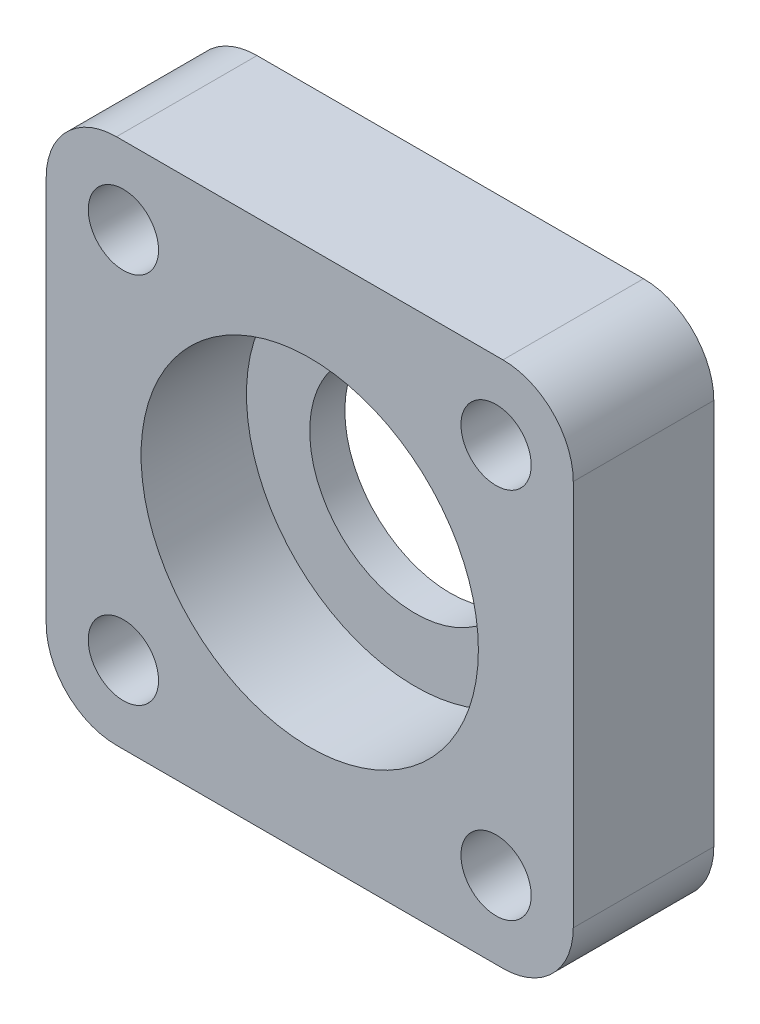
from build123d import *

# Parameters (mm, degrees)
SKETCH1_W           = 30
SKETCH1_H           = 30
SKETCH1_R           = 2
BOSS_EXTRUDE1_DEPTH = 8
SKETCH2_R           = 9.6
CUT_EXTRUDE1_DEPTH  = 6
SKETCH3_R           = 6
CUT_EXTRUDE2_DEPTH  = 7
FILLET1_R           = 4


with BuildPart() as part:
    # Sketch1 → Boss-Extrude1 (new body)
    with BuildSketch(Plane.XY):
        with Locations((15, 15)):
            Rectangle(SKETCH1_W, SKETCH1_H)
        with Locations((25.606601718, 25.606601718)):
            Circle(SKETCH1_R, mode=Mode.SUBTRACT)
        with Locations((25.606601718, 4.393398282)):
            Circle(SKETCH1_R, mode=Mode.SUBTRACT)
        with Locations((4.393398282, 4.393398282)):
            Circle(SKETCH1_R, mode=Mode.SUBTRACT)
        with Locations((4.393398282, 25.606601718)):
            Circle(SKETCH1_R, mode=Mode.SUBTRACT)
    extrude(amount=BOSS_EXTRUDE1_DEPTH)

    # Sketch2 → Cut-Extrude1 (cut)
    with BuildSketch(Plane.XY.offset(8)):
        with Locations((15, 15)):
            Circle(SKETCH2_R)
    extrude(amount=-CUT_EXTRUDE1_DEPTH, mode=Mode.SUBTRACT)

    # Sketch3 → Cut-Extrude2 (cut)
    with BuildSketch(Plane.XY.offset(2)):
        with Locations((15, 15)):
            Circle(SKETCH3_R)
    extrude(amount=-CUT_EXTRUDE2_DEPTH, mode=Mode.SUBTRACT)

    # Fillet1
    fillet1_edges = [part.edges().sort_by_distance(p)[0] for p in [
        (0, 30, 4),
        (30, 30, 4),
        (30, 0, 4),
        (0, 0, 4),
    ]]
    fillet(fillet1_edges, radius=FILLET1_R)


solid = part.part
